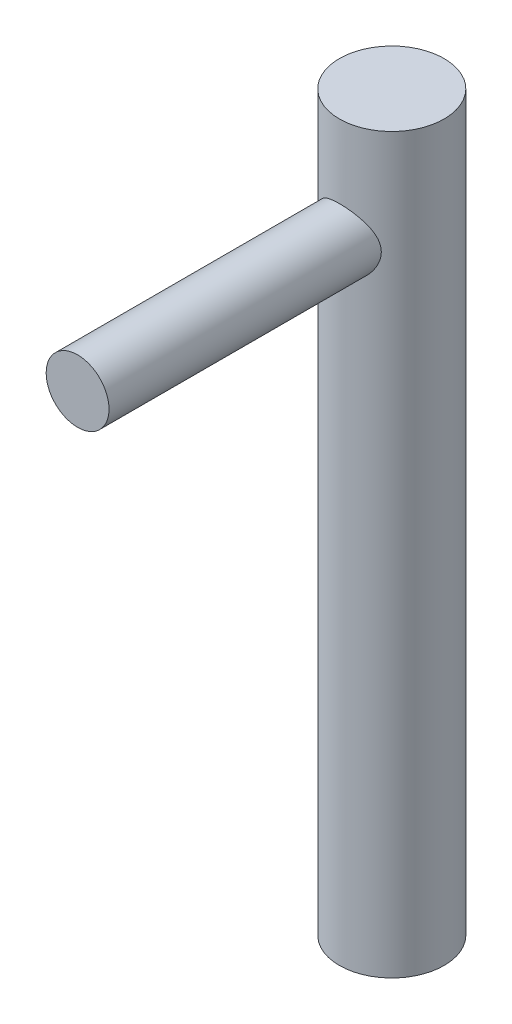
from build123d import *

# Parameters (mm, degrees)
SKETCH1_R           = 2.5
BOSS_EXTRUDE1_DEPTH = 35
SKETCH4_R           = 1.5
BOSS_EXTRUDE3_DEPTH = 15


with BuildPart() as part:
    # Sketch1 → Boss-Extrude1 (new body)
    with BuildSketch(Plane(origin=(0, 0, 0), x_dir=(1, 0, 0), z_dir=(0, 1, 0))):
        Circle(SKETCH1_R)
    extrude(amount=BOSS_EXTRUDE1_DEPTH)

    # Sketch4 → Boss-Extrude3 (add)
    with BuildSketch(Plane.XY):
        with Locations((0, 30)):
            Circle(SKETCH4_R)
    extrude(amount=BOSS_EXTRUDE3_DEPTH)


solid = part.part
